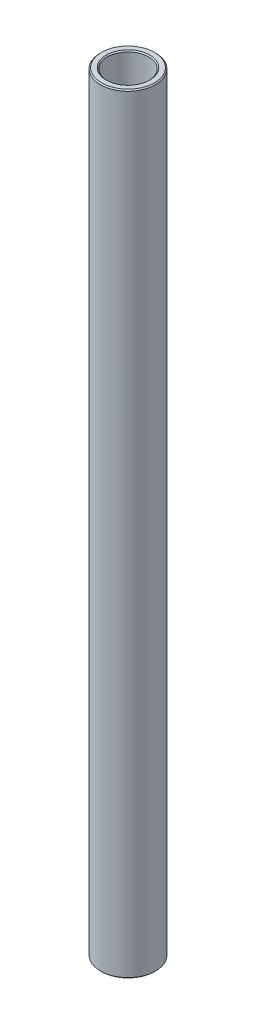
from build123d import *

# Parameters (mm, degrees)
SKETCH1_W     = 1.5875
SKETCH1_H     = 177.460231939
CHAMFER1_SIZE = 0.254


with BuildPart() as part:
    # Sketch1 → Revolve1 (revolve)
    with BuildSketch(Plane.XY):
        with Locations((5.55625, 98.25511597)):
            Rectangle(SKETCH1_W, SKETCH1_H)
    revolve(axis=Axis((0, 0, 0), (0, 1, 0)))

    # Chamfer1
    chamfer1_edges = [part.edges().sort_by_distance(p)[0] for p in [
        (-6.35, 9.525, 0),
        (-6.35, 186.985231939, 0),
        (-4.7625, 186.985231939, 0),
        (-4.7625, 9.525, 0),
    ]]
    chamfer(chamfer1_edges, length=CHAMFER1_SIZE)


solid = part.part
